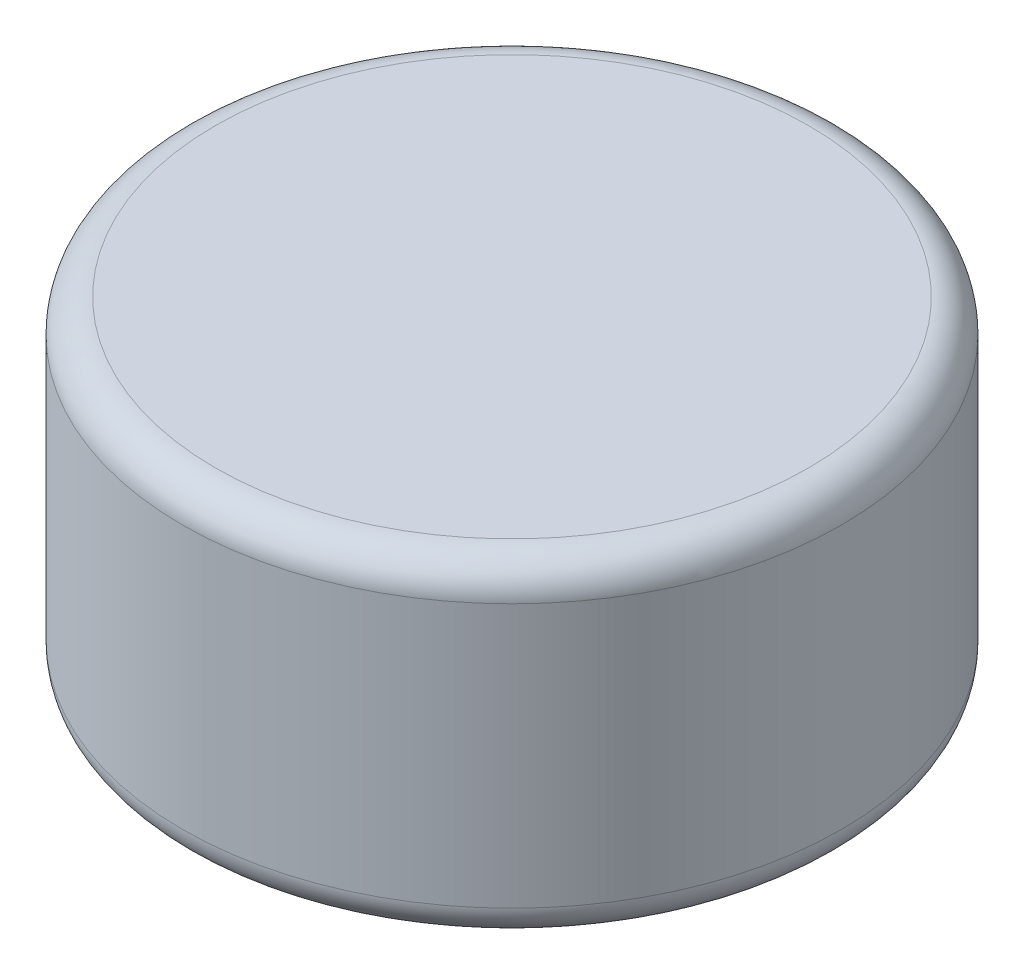
from build123d import *

# Parameters (mm, degrees)
SKETCH1_R           = 3.175
BOSS_EXTRUDE1_DEPTH = 1.5875
FILLET1_R           = 0.3175


with BuildPart() as part:
    # Sketch1 → Boss-Extrude1 (new body, symmetric)
    with BuildSketch(Plane(origin=(0, 0, 0), x_dir=(1, 0, 0), z_dir=(0, 1, 0))):
        Circle(SKETCH1_R)
    extrude(amount=BOSS_EXTRUDE1_DEPTH, both=True)

    # Fillet1
    fillet1_edges = [part.edges().sort_by_distance(p)[0] for p in [
        (-3.175, -1.5875, 0),
        (-3.175, 1.5875, 0),
    ]]
    fillet(fillet1_edges, radius=FILLET1_R)


solid = part.part
